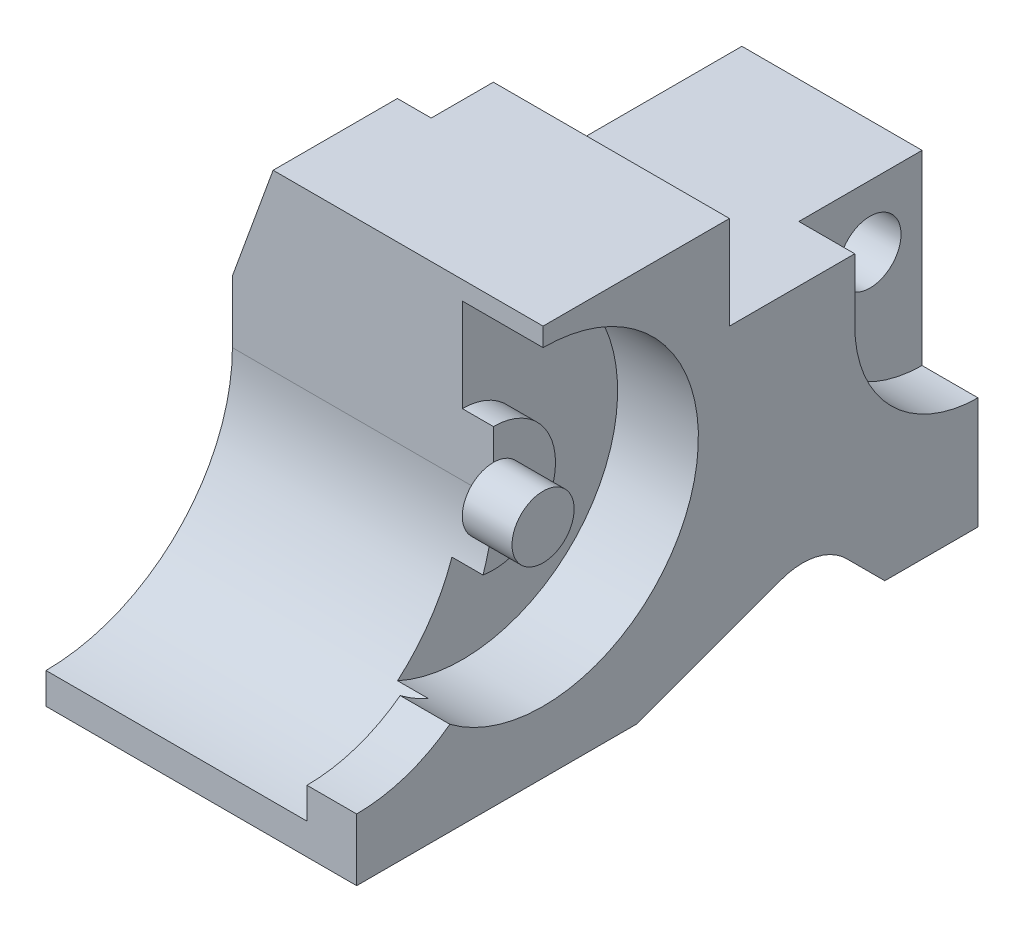
from build123d import *

# Parameters (mm, degrees)
SKETCH1_W           = 100
SKETCH1_H           = 63
BOSS_EXTRUDE1_DEPTH = 50
SKETCH2_W           = 50
SKETCH2_H           = 40
CUT_EXTRUDE1_DEPTH  = 15
SKETCH3_W           = 12
SKETCH3_H           = 10
CUT_EXTRUDE2_DEPTH  = 15
CUT_EXTRUDE3_DEPTH  = 9
SKETCH5_R           = 5
CUT_EXTRUDE4_DEPTH  = 42
CUT_EXTRUDE5_DEPTH  = 51
CUT_EXTRUDE6_DEPTH  = 42
CUT_EXTRUDE10_DEPTH = 51
CUT_EXTRUDE16_DEPTH = 13
CUT_EXTRUDE17_DEPTH = 8
SKETCH11_10_R       = 5
BOSS_EXTRUDE5_DEPTH = 8
CUT_EXTRUDE18_DEPTH = 20
CUT_EXTRUDE22_DEPTH = 8
SKETCH16_W          = 12
SKETCH16_H          = 50
CUT_EXTRUDE23_DEPTH = 49


with BuildPart() as part:
    # Sketch1 → Boss-Extrude1 (new body)
    with BuildSketch(Plane(origin=(0, 0, 0), x_dir=(0, 0, -1), z_dir=(1, 0, 0))):
        with Locations((6.649757701, 6.248490946)):
            Rectangle(SKETCH1_W, SKETCH1_H)
    extrude(amount=-BOSS_EXTRUDE1_DEPTH)

    # Sketch2 → Cut-Extrude1 (cut)
    with BuildSketch(Plane(origin=(0, 37.748490946, 0), x_dir=(1, 0, 0), z_dir=(0, 1, 0))):
        with Locations((-25, 36.649757701)):
            Rectangle(SKETCH2_W, SKETCH2_H)
    extrude(amount=-CUT_EXTRUDE1_DEPTH, mode=Mode.SUBTRACT)

    # Sketch3 → Cut-Extrude2 (cut)
    with BuildSketch(Plane(origin=(0, 37.748490946, 0), x_dir=(1, 0, 0), z_dir=(0, 1, 0))):
        with Locations((-44, 11.649757701)):
            Rectangle(SKETCH3_W, SKETCH3_H)
    extrude(amount=-CUT_EXTRUDE2_DEPTH, mode=Mode.SUBTRACT)

    # Sketch4 → Cut-Extrude3 (cut)
    with BuildSketch(Plane(origin=(0, 0, 0), x_dir=(0, 0, -1), z_dir=(1, 0, 0))):
        with BuildLine():
            Line((36.814050896, 22.748490946), (36.814050896, 12.748490946))
            ThreePointArc((36.814050896, 12.748490946), (42.613947659, -1.335438479), (56.649757701, -7.250834237))
            Line((56.649757701, -7.250834237), (56.649757701, 22.748490946))
            Line((56.649757701, 22.748490946), (36.814050896, 22.748490946))
        make_face()
    extrude(amount=-CUT_EXTRUDE3_DEPTH, mode=Mode.SUBTRACT)

    # Sketch5 → Cut-Extrude4 (cut, through all)
    with BuildSketch(Plane(origin=(-9, 0, 0), x_dir=(0, 0, -1), z_dir=(1, 0, 0))):
        with Locations((48.259112346, 12.748490946)):
            Circle(SKETCH5_R)
    extrude(amount=-CUT_EXTRUDE4_DEPTH, mode=Mode.SUBTRACT)

    # Sketch6 → Cut-Extrude5 (cut, through all)
    with BuildSketch(Plane(origin=(0, 0, 0), x_dir=(0, 0, -1), z_dir=(1, 0, 0))):
        with BuildLine():
            Line((41.649757701, -25.251509054), (35.480677879, -19.082429233))
            ThreePointArc((35.480677879, -19.082429233), (30.574006207, -16.390536973), (24.989408634, -16.756570837))
            Line((24.989408634, -16.756570837), (1.649757701, -25.251509054))
            Line((1.649757701, -25.251509054), (41.649757701, -25.251509054))
        make_face()
    extrude(amount=-CUT_EXTRUDE5_DEPTH, mode=Mode.SUBTRACT)

    # Sketch8 → Cut-Extrude6 (cut)
    with BuildSketch(Plane.ZY.offset(50)):
        with BuildLine():
            Line((43.350242299, -20.251509054), (43.350242299, 9.748490946))
            Line((43.350242299, 9.748490946), (13.350242299, 9.748490946))
            ThreePointArc((13.350242299, 9.748490946), (22.137038863, -11.46471249), (43.350242299, -20.251509054))
        make_face()
    extrude(amount=-CUT_EXTRUDE6_DEPTH, mode=Mode.SUBTRACT)

    # Sketch8_5 → Cut-Extrude10 (cut, through all)
    with BuildSketch(Plane.ZY.offset(50)):
        Polygon((13.350242299, 9.748490946), (43.350242299, 9.748490946), (43.350242299, 37.748490946), (36.798778082, 37.748490946), (13.350242299, 37.748490946), align=None)
    extrude(amount=-CUT_EXTRUDE10_DEPTH, mode=Mode.SUBTRACT)

    # Sketch11 → Cut-Extrude16 (cut)
    with BuildSketch(Plane(origin=(0, 0, 0), x_dir=(0, 0, -1), z_dir=(1, 0, 0))):
        with BuildLine():
            ThreePointArc((-23.350242299, 9.748490946), (-20.421310111, 16.819558758), (-13.350242299, 19.748490946))
            Line((-13.350242299, 19.748490946), (-13.350242299, 34.748490946))
            ThreePointArc((-13.350242299, 34.748490946), (-31.027911829, 27.426160475), (-38.350242299, 9.748490946))
            Line((-38.350242299, 9.748490946), (-23.350242299, 9.748490946))
        make_face()
        with BuildLine():
            Line((-13.350242299, 34.748490946), (-13.350242299, 19.748490946))
            ThreePointArc((-13.350242299, 19.748490946), (-6.279174487, 16.819558758), (-3.350242299, 9.748490946))
            ThreePointArc((-3.350242299, 9.748490946), (-13.350242299, -0.251509054), (-23.350242299, 9.748490946))
            Line((-23.350242299, 9.748490946), (-38.350242299, 9.748490946))
            ThreePointArc((-38.350242299, 9.748490946), (-35.710922074, -1.431848942), (-28.350242299, -10.251509054))
            ThreePointArc((-28.350242299, -10.251509054), (-2.169902411, -12.612188829), (11.649757701, 9.748490946))
            ThreePointArc((11.649757701, 9.748490946), (4.327427231, 27.426160475), (-13.350242299, 34.748490946))
        make_face()
    extrude(amount=-CUT_EXTRUDE16_DEPTH, mode=Mode.SUBTRACT)

    # Sketch11_8 → Cut-Extrude17 (cut)
    with BuildSketch(Plane(origin=(0, 0, 0), x_dir=(0, 0, -1), z_dir=(1, 0, 0))):
        with BuildLine():
            ThreePointArc((-3.350242299, 9.748490946), (-6.279174487, 16.819558758), (-13.350242299, 19.748490946))
            Line((-13.350242299, 19.748490946), (-13.350242299, 14.748490946))
            ThreePointArc((-13.350242299, 14.748490946), (-9.814708393, 13.284024852), (-8.350242299, 9.748490946))
            ThreePointArc((-8.350242299, 9.748490946), (-13.350242299, 4.748490946), (-18.350242299, 9.748490946))
            Line((-18.350242299, 9.748490946), (-23.350242299, 9.748490946))
            ThreePointArc((-23.350242299, 9.748490946), (-13.350242299, -0.251509054), (-3.350242299, 9.748490946))
        make_face()
    extrude(amount=-CUT_EXTRUDE17_DEPTH, mode=Mode.SUBTRACT)

    # Sketch11_10 → Boss-Extrude5 (add)
    with BuildSketch(Plane(origin=(0, 0, 0), x_dir=(0, 0, -1), z_dir=(1, 0, 0))):
        with Locations((-13.350242299, 9.748490946)):
            Circle(SKETCH11_10_R)
    extrude(amount=-BOSS_EXTRUDE5_DEPTH)

    # Sketch14 → Cut-Extrude18 (cut)
    with BuildSketch(Plane.XY.offset(13.350242299)):
        Polygon((-50, 19.748490946), (-43.448535783, 37.748490946), (-50, 37.748490946), align=None)
    extrude(amount=-CUT_EXTRUDE18_DEPTH, mode=Mode.SUBTRACT)

    # Sketch11_11 → Cut-Extrude22 (cut)
    with BuildSketch(Plane(origin=(0, 0, 0), x_dir=(0, 0, -1), z_dir=(1, 0, 0))):
        with BuildLine():
            ThreePointArc((-28.350242299, -10.251509054), (-35.710922074, -1.431848942), (-38.350242299, 9.748490946))
            Line((-38.350242299, 9.748490946), (-43.350242299, 9.748490946))
            Line((-43.350242299, 9.748490946), (-43.350242299, -15.251509054))
            ThreePointArc((-43.350242299, -15.251509054), (-35.444548148, -13.968591506), (-28.350242299, -10.251509054))
        make_face()
    extrude(amount=-CUT_EXTRUDE22_DEPTH, mode=Mode.SUBTRACT)

    # Sketch16 → Cut-Extrude23 (cut, through all)
    with BuildSketch(Plane(origin=(0, 22.748490946, 0), x_dir=(1, 0, 0), z_dir=(0, 1, 0))):
        with Locations((-44, 31.649757701)):
            Rectangle(SKETCH16_W, SKETCH16_H)
    extrude(amount=-CUT_EXTRUDE23_DEPTH, mode=Mode.SUBTRACT)


solid = part.part
